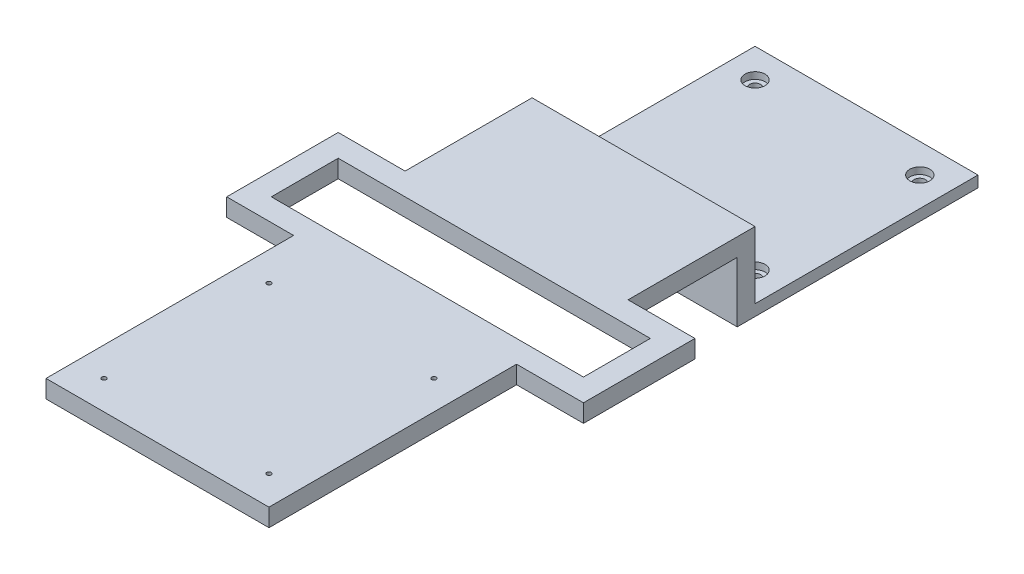
from build123d import *

# Parameters (mm, degrees)
SKETCH1_W           = 100
SKETCH1_H           = 100
SKETCH1_R           = 2.5
BOSS_EXTRUDE1_DEPTH = 5
CUT_EXTRUDE1_START  = -5
SKETCH6_R           = 4.5
CUT_EXTRUDE1_DEPTH  = 3
SKETCH8_W           = 8
SKETCH8_H           = 35
BOSS_EXTRUDE2_DEPTH = 100
SKETCH9_W           = 100
SKETCH9_H           = 8
BOSS_EXTRUDE3_DEPTH = 210
SKETCH10_W          = 160
SKETCH10_H          = 50
BOSS_EXTRUDE4_DEPTH = 8
SKETCH11_W          = 140
SKETCH11_H          = 30
CUT_EXTRUDE2_DEPTH  = 8
SKETCH13_R          = 1
CUT_EXTRUDE3_DEPTH  = 8


with BuildPart() as part:
    # Sketch1 → Boss-Extrude1 (new body)
    with BuildSketch(Plane(origin=(0, 0, 0), x_dir=(1, 0, 0), z_dir=(0, 1, 0))):
        Rectangle(SKETCH1_W, SKETCH1_H)
        with Locations((-36.95, 36.95)):
            Circle(SKETCH1_R, mode=Mode.SUBTRACT)
        with Locations((36.95, 36.95)):
            Circle(SKETCH1_R, mode=Mode.SUBTRACT)
        with Locations((36.95, -36.95)):
            Circle(SKETCH1_R, mode=Mode.SUBTRACT)
        with Locations((-36.95, -36.95)):
            Circle(SKETCH1_R, mode=Mode.SUBTRACT)
    extrude(amount=BOSS_EXTRUDE1_DEPTH)

    # Sketch6 → Cut-Extrude1 (cut)
    with BuildSketch(Plane.XZ.offset(CUT_EXTRUDE1_START)):
        with Locations((-36.95, 36.95)):
            Circle(SKETCH6_R)
        with Locations((36.95, 36.95)):
            Circle(SKETCH6_R)
        with Locations((36.95, -36.95)):
            Circle(SKETCH6_R)
        with Locations((-36.95, -36.95)):
            Circle(SKETCH6_R)
    extrude(amount=CUT_EXTRUDE1_DEPTH, mode=Mode.SUBTRACT)

    # Sketch8 → Boss-Extrude2 (add, through all)
    with BuildSketch(Plane.ZY.offset(50)):
        with Locations((54, 17.5)):
            Rectangle(SKETCH8_W, SKETCH8_H)
    extrude(amount=-BOSS_EXTRUDE2_DEPTH)

    # Sketch9 → Boss-Extrude3 (add)
    with BuildSketch(Plane.XY.offset(58)):
        with Locations((0, 31)):
            Rectangle(SKETCH9_W, SKETCH9_H)
    extrude(amount=BOSS_EXTRUDE3_DEPTH)

    # Sketch10 → Boss-Extrude4 (add)
    with BuildSketch(Plane(origin=(0, 35, 0), x_dir=(1, 0, 0), z_dir=(0, 1, 0))):
        with Locations((0, -131.95)):
            Rectangle(SKETCH10_W, SKETCH10_H)
    extrude(amount=-BOSS_EXTRUDE4_DEPTH)

    # Sketch11 → Cut-Extrude2 (cut)
    with BuildSketch(Plane(origin=(0, 35, 0), x_dir=(1, 0, 0), z_dir=(0, 1, 0))):
        with Locations((0, -131.95)):
            Rectangle(SKETCH11_W, SKETCH11_H)
    extrude(amount=-CUT_EXTRUDE2_DEPTH, mode=Mode.SUBTRACT)

    # Sketch13 → Cut-Extrude3 (cut)
    with BuildSketch(Plane(origin=(0, 35, 0), x_dir=(1, 0, 0), z_dir=(0, 1, 0))):
        with Locations((-37, -181)):
            Circle(SKETCH13_R)
        with Locations((37, -181)):
            Circle(SKETCH13_R)
        with Locations((37, -255)):
            Circle(SKETCH13_R)
        with Locations((-37, -255)):
            Circle(SKETCH13_R)
    extrude(amount=-CUT_EXTRUDE3_DEPTH, mode=Mode.SUBTRACT)


solid = part.part
